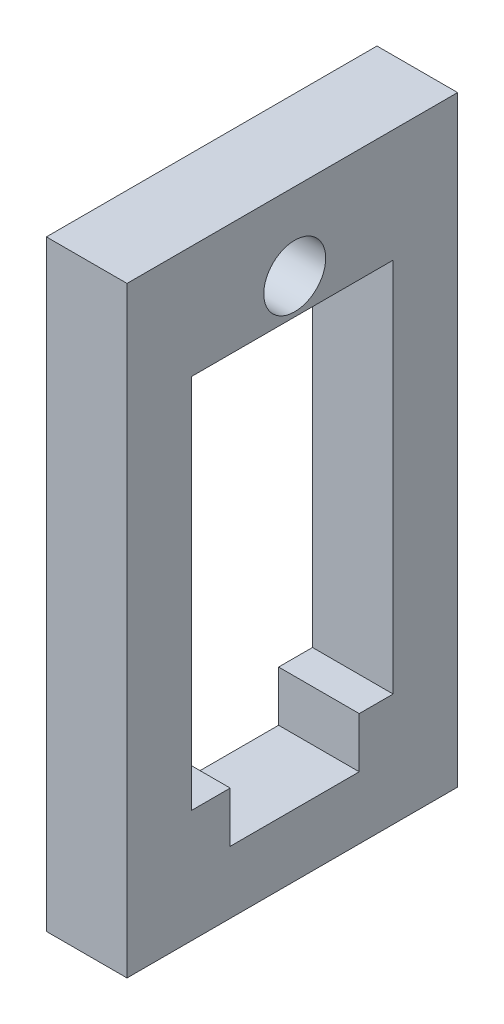
from build123d import *

# Parameters (mm, degrees)
SKETCH1_W           = 20.5
SKETCH1_H           = 37.3
SKETCH1_W_2         = 12.5
SKETCH1_H_2         = 23.3
BOSS_EXTRUDE1_DEPTH = 5
SKETCH2_R           = 1.92
CUT_EXTRUDE1_DEPTH  = 13
SKETCH4_W           = 8
SKETCH4_H           = 3.126799126
CUT_EXTRUDE3_DEPTH  = 20


with BuildPart() as part:
    # Sketch1 → Boss-Extrude1 (new body)
    with BuildSketch(Plane(origin=(0, 0, 0), x_dir=(0, 0, -1), z_dir=(1, 0, 0))):
        with Locations((-0.15, -0.4)):
            Rectangle(SKETCH1_W, SKETCH1_H)
        with Locations((-0.15, -0.4)):
            Rectangle(SKETCH1_W_2, SKETCH1_H_2, mode=Mode.SUBTRACT)
    extrude(amount=BOSS_EXTRUDE1_DEPTH)

    # Sketch2 → Cut-Extrude1 (cut)
    with BuildSketch(Plane(origin=(5, 0, 0), x_dir=(0, 0, -1), z_dir=(1, 0, 0))):
        with Locations((0, 13.45)):
            Circle(SKETCH2_R)
    extrude(amount=-CUT_EXTRUDE1_DEPTH, mode=Mode.SUBTRACT)

    # Sketch4 → Cut-Extrude3 (cut)
    with BuildSketch(Plane(origin=(5, 0, 0), x_dir=(0, 0, -1), z_dir=(1, 0, 0))):
        with Locations((0, -13.613399563)):
            Rectangle(SKETCH4_W, SKETCH4_H)
    extrude(amount=-CUT_EXTRUDE3_DEPTH, mode=Mode.SUBTRACT)


solid = part.part
